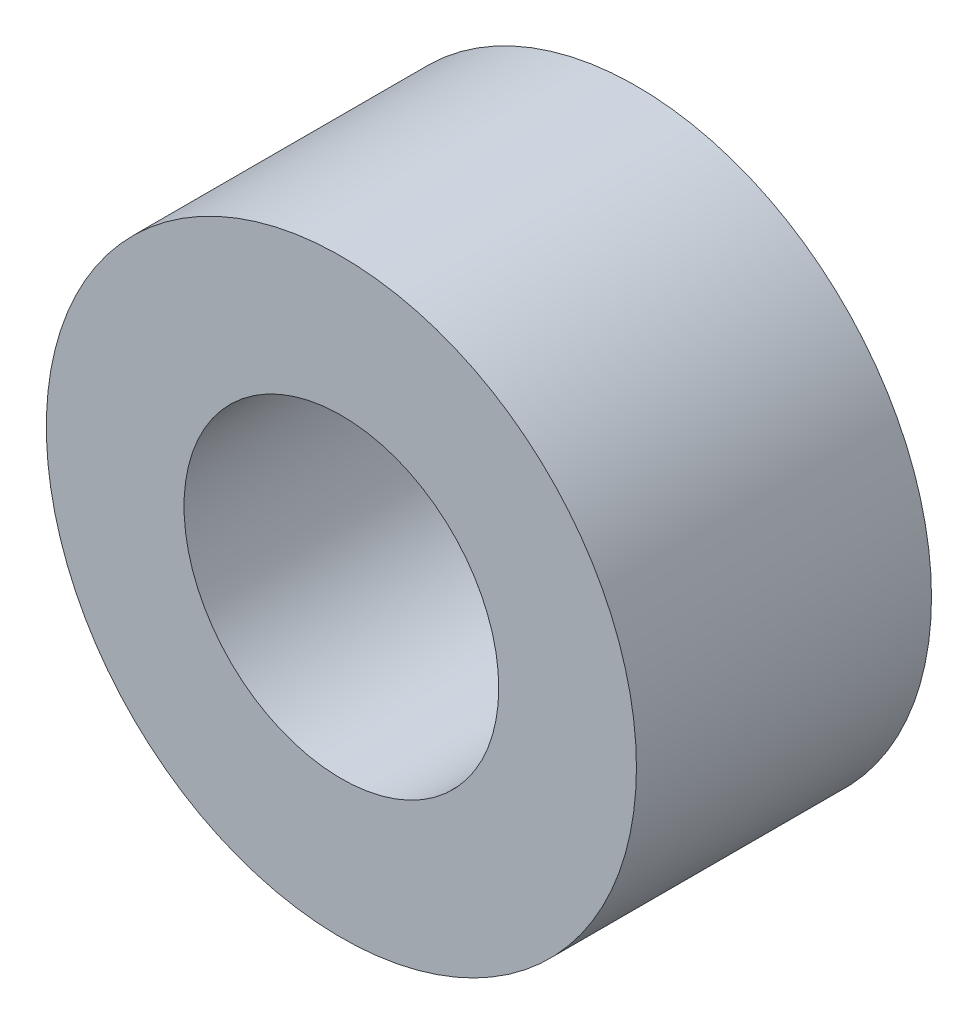
from build123d import *

# Parameters (mm, degrees)
SKETCH_1_R      = 3
SKETCH_1_R_2    = 1.6
EXTRUDE_1_DEPTH = 3


with BuildPart() as part:
    # ｽｹｯﾁ1 → ﾎﾞｽ - 押し出し1 (new body)
    with BuildSketch(Plane.XY):
        Circle(SKETCH_1_R)
        Circle(SKETCH_1_R_2, mode=Mode.SUBTRACT)
    extrude(amount=EXTRUDE_1_DEPTH)


solid = part.part
